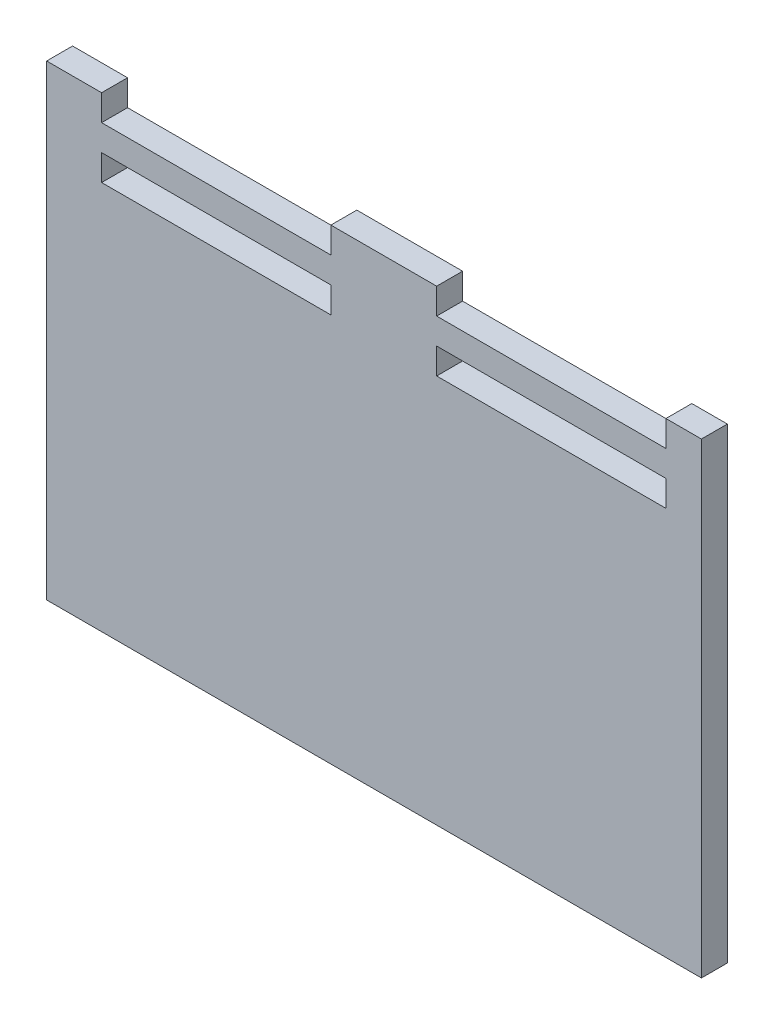
from build123d import *

# Parameters (mm, degrees)
SKETCH1_W           = 304.8
SKETCH1_H           = 228.6
BOSS_EXTRUDE1_DEPTH = 12.7
SKETCH7_W           = 112.268
SKETCH7_H           = 12.7
CUT_EXTRUDE2_DEPTH  = 12.7
SKETCH8_W           = 12.7
SKETCH8_H           = 228.6
SKETCH8_W_2         = 3.175
BOSS_EXTRUDE2_DEPTH = 12.7


with BuildPart() as part:
    # Sketch1 → Boss-Extrude1 (new body)
    with BuildSketch(Plane.XY):
        with Locations((152.4, 114.3)):
            Rectangle(SKETCH1_W, SKETCH1_H)
    extrude(amount=BOSS_EXTRUDE1_DEPTH)

    # Sketch7 → Cut-Extrude2 (cut)
    with BuildSketch(Plane.XY.offset(12.7)):
        with Locations((70.358, 222.25)):
            Rectangle(SKETCH7_W, SKETCH7_H)
        with Locations((234.442, 222.25)):
            Rectangle(SKETCH7_W, SKETCH7_H)
        with Locations((70.358, 196.85)):
            Rectangle(SKETCH7_W, SKETCH7_H)
        with Locations((234.442, 196.85)):
            Rectangle(SKETCH7_W, SKETCH7_H)
    extrude(amount=-CUT_EXTRUDE2_DEPTH, mode=Mode.SUBTRACT)

    # Sketch8 → Boss-Extrude2 (add)
    with BuildSketch(Plane.XY.offset(12.7)):
        with Locations((-6.35, 114.3)):
            Rectangle(SKETCH8_W, SKETCH8_H)
        with Locations((306.3875, 114.3)):
            Rectangle(SKETCH8_W_2, SKETCH8_H)
    extrude(amount=-BOSS_EXTRUDE2_DEPTH)


solid = part.part
